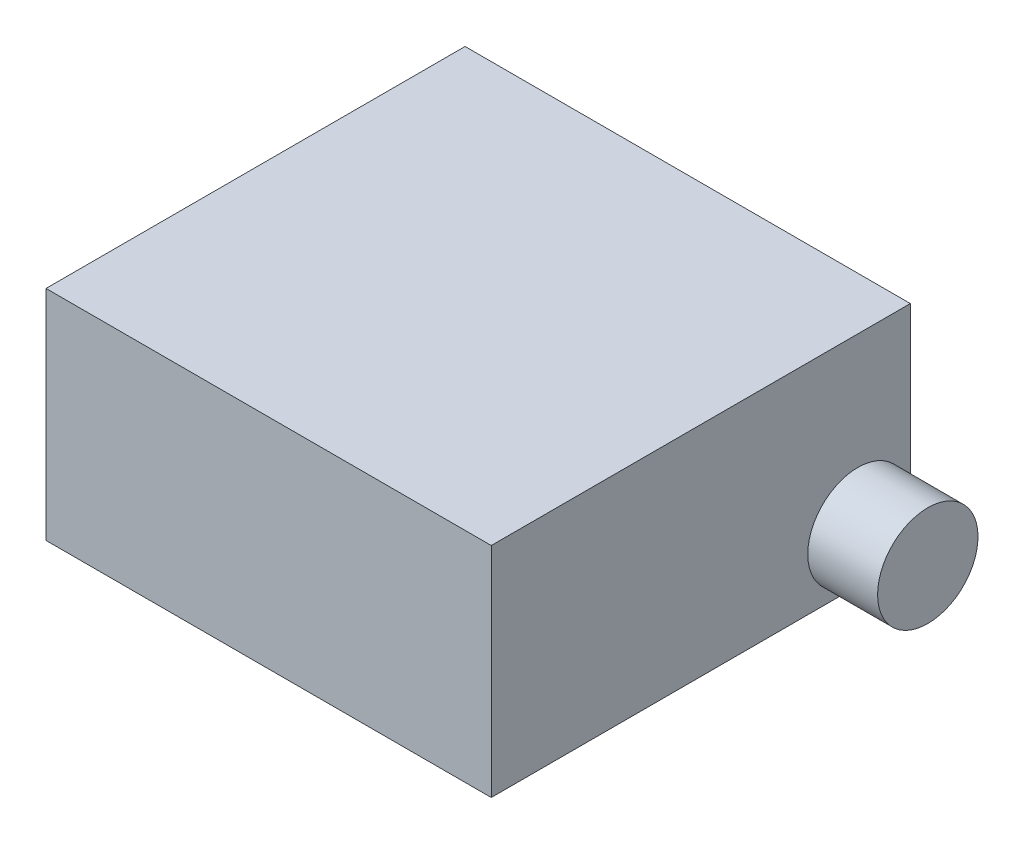
from build123d import *

# Parameters (mm, degrees)
SKETCH1_W           = 10.2
SKETCH1_H           = 9.6
BOSS_EXTRUDE1_DEPTH = 5
SKETCH2_R           = 1.15
BOSS_EXTRUDE2_DEPTH = 1.6


with BuildPart() as part:
    # Sketch1 → Boss-Extrude1 (new body)
    with BuildSketch(Plane(origin=(0, 0, 0), x_dir=(1, 0, 0), z_dir=(0, 1, 0))):
        with Locations((5.1, 4.8)):
            Rectangle(SKETCH1_W, SKETCH1_H)
    extrude(amount=BOSS_EXTRUDE1_DEPTH)

    # Sketch2 → Boss-Extrude2 (add)
    with BuildSketch(Plane(origin=(10.2, 0, 0), x_dir=(0, 0, -1), z_dir=(1, 0, 0))):
        with Locations((8.4, 1.2)):
            Circle(SKETCH2_R)
    extrude(amount=BOSS_EXTRUDE2_DEPTH)


solid = part.part
